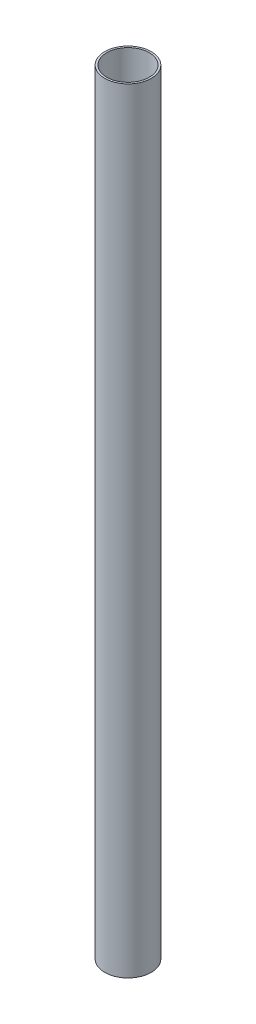
from build123d import *

# Parameters (mm, degrees)
ESBO_O1_R                     = 30
ESBO_O1_R_2                   = 27.5
RESSALTO_EXTRUS_O1_DEPTH      = 940
RESSALTO_EXTRUS_O1_DEPTH_BACK = 60


with BuildPart() as part:
    # Esboço1 → Ressalto-extrusão1 (new body, two sides)
    with BuildSketch(Plane(origin=(0, 0, 0), x_dir=(1, 0, 0), z_dir=(0, 1, 0))) as ressalto_extrus_o1_sk:
        Circle(ESBO_O1_R)
        Circle(ESBO_O1_R_2, mode=Mode.SUBTRACT)
    extrude(amount=RESSALTO_EXTRUS_O1_DEPTH)
    extrude(ressalto_extrus_o1_sk.sketch, amount=-RESSALTO_EXTRUS_O1_DEPTH_BACK)


solid = part.part
